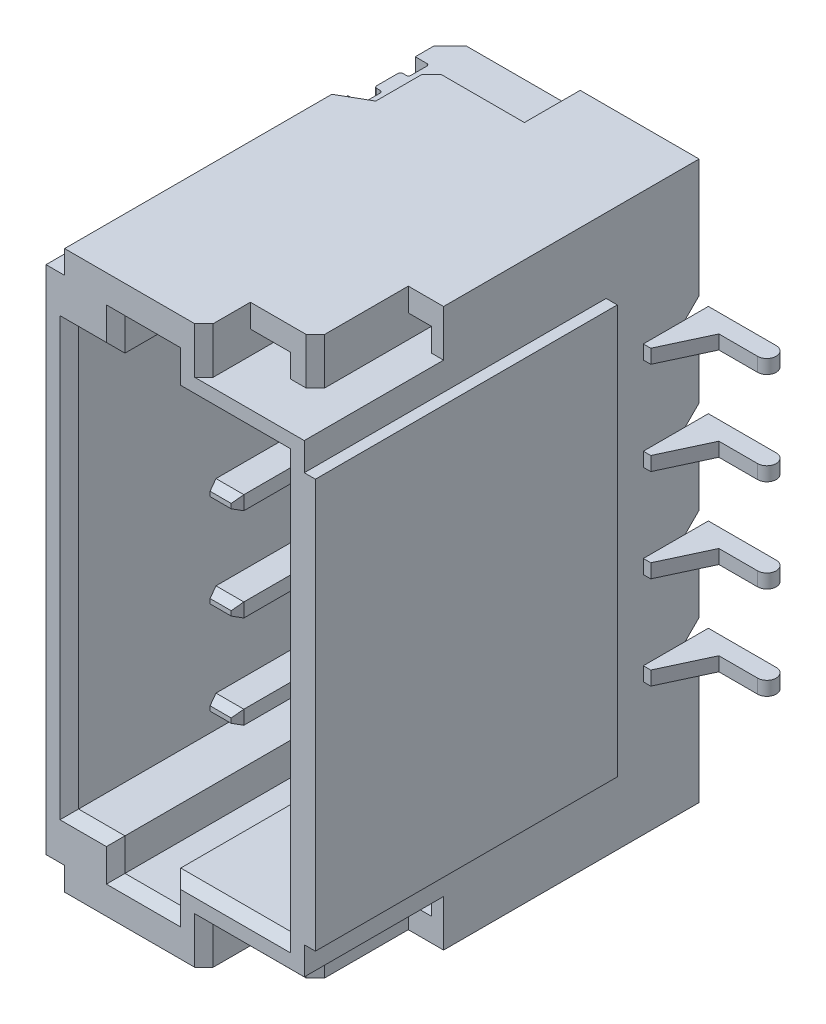
from build123d import *

# Parameters (mm, degrees)
BOSS_EXTRUDE2_START      = -0.815
BOSS_EXTRUDE2_DEPTH      = 0.15
BOSS_EXTRUDE3_START      = 2.26
BOSS_EXTRUDE3_DEPTH      = 0.2
BOSS_EXTRUDE4_START      = 1.76
SKETCH4_W                = 2.899999619
SKETCH4_H                = 6
BOSS_EXTRUDE4_DEPTH      = 4.25
CUT_EXTRUDE2_DEPTH       = 4.610000193
LPATTERN1_COUNT          = 4
LPATTERN1_PITCH          = 1
SKETCH6_OUTSIDE_W        = 7.998
SKETCH6_OUTSIDE_H        = 9.648
SKETCH6_OUTSIDE_W_2      = 3.400752587
SKETCH6_OUTSIDE_H_2      = 4.399999618
CUT_EXTRUDE3_DEPTH       = 0.12
SKETCH7_W                = 2.280000687
SKETCH7_H                = 4.5
CUT_EXTRUDE4_DEPTH       = 3.2
SKETCH8_W                = 0.600000381
SKETCH8_H                = 0.349998474
SKETCH8_H_2              = 0.350000382
CUT_EXTRUDE6_DEPTH       = 2.6
CHAMFER1_SIZE            = 0.1
BOSS_EXTRUDE5_START      = -1.82
BOSS_EXTRUDE5_DEPTH      = 0.15
CHAMFER2_SIZE            = 0.1
CHAMFER2_SIZE2           = 0.05
CHAMFER3_SIZE            = 0.05
CHAMFER3_SIZE2           = 0.1
LPATTERN2_COUNT          = 4
LPATTERN2_PITCH          = 1
SKETCH10_W               = 4.538557702
SKETCH10_H               = 0.25
SKETCH10_W_2             = 4.80487801
CUT_EXTRUDE7_DEPTH       = 0.2
CUT_EXTRUDE8_DEPTH       = 0.5
SKETCH12_W               = 0.600000143
SKETCH12_H               = 0.25
CUT_EXTRUDE9_DEPTH       = 1
CHAMFER4_SIZE            = 0.1
CHAMFER5_SIZE            = 0.1
CHAMFER4_OF_MIRROR1_SIZE = 0.1
CHAMFER5_OF_MIRROR1_SIZE = 0.1
CUT_EXTRUDE10_DEPTH      = 0.5
CHAMFER6_SIZE            = 0.1
SKETCH14_W               = 0.431049877
SKETCH14_H               = 0.25
SKETCH14_W_2             = 0.251151421
CUT_EXTRUDE11_DEPTH      = 2
CHAMFER6_OF_MIRROR3_SIZE = 0.1


with BuildPart() as part:
    # Sketch2 → Boss-Extrude2 (new body)
    with BuildSketch(Plane(origin=(0, 0, 0), x_dir=(1, 0, 0), z_dir=(0, 1, 0)).offset(BOSS_EXTRUDE2_START)):
        with BuildLine():
            Line((22.630613327, -2.360296965), (22.630613327, -1.910297036))
            Line((22.630613327, -1.910297036), (25.410614014, -1.910297036))
            Line((25.410614014, -1.910297036), (25.410614014, -1.660297036))
            Line((25.410614014, -1.660297036), (26.140613556, -1.660297036))
            ThreePointArc((26.140613556, -1.660297036), (26.24061352, -1.760297), (26.140613556, -1.860296965))
            Line((26.140613556, -1.860296965), (25.723766327, -1.860296965))
            Line((25.723766327, -1.860296965), (25.490613937, -2.360296965))
            Line((25.490613937, -2.360296965), (22.630613327, -2.360296965))
        make_face()
    extrude(amount=BOSS_EXTRUDE2_DEPTH)


with BuildPart() as body_2:
    # Body-Move/Copy2: copy of part
    add(part.part.moved(Location((0, -1, 0))))


with BuildPart() as body_3:
    # Body-Move/Copy3: copy of part
    add(part.part.moved(Location((0, 1, 0))))


with BuildPart() as body_4:
    # Body-Move/Copy4: copy of body 3
    add(body_3.part.moved(Location((0, 1, 0))))


with BuildPart() as body_5:
    # Sketch3 → Boss-Extrude3 (new body)
    with BuildSketch(Plane(origin=(0, 0, 0), x_dir=(1, 0, 0), z_dir=(0, 1, 0)).offset(BOSS_EXTRUDE3_START)):
        with BuildLine():
            Line((22.730613708, -2.960297108), (24.130613327, -2.960297108))
            Line((24.130613327, -2.960297108), (24.130613327, -1.835296988))
            Line((24.130613327, -1.835296988), (23.955612183, -1.660297036))
            Line((23.955612183, -1.660297036), (22.805612564, -1.660297036))
            Line((22.805612564, -1.660297036), (22.630613327, -1.835296988))
            Line((22.630613327, -1.835296988), (22.630613327, -2.035296917))
            Line((22.630613327, -2.035296917), (22.755613327, -2.035296917))
            ThreePointArc((22.755613327, -2.035296917), (22.773290756, -2.042619444), (22.780612946, -2.060297012))
            Line((22.780612946, -2.060297012), (22.780612946, -2.232796907))
            ThreePointArc((22.780612946, -2.232796907), (22.773287217, -2.250482782), (22.755601342, -2.257808511))
            Line((22.755601342, -2.257808511), (22.718101914, -2.257808511))
            ThreePointArc((22.718101914, -2.257808511), (22.700432315, -2.265127499), (22.693113327, -2.282797098))
            Line((22.693113327, -2.282797098), (22.693113327, -2.512797117))
            ThreePointArc((22.693113327, -2.512797117), (22.700435531, -2.530474601), (22.718112946, -2.537796974))
            Line((22.718112946, -2.537796974), (22.755613327, -2.537796974))
            ThreePointArc((22.755613327, -2.537796974), (22.773290895, -2.545119362), (22.780612946, -2.56279707))
            Line((22.780612946, -2.56279707), (22.780612946, -2.735296965))
            ThreePointArc((22.780612946, -2.735296965), (22.773290756, -2.752974533), (22.755613327, -2.76029706))
            Line((22.755613327, -2.76029706), (22.630613327, -2.76029706))
            Line((22.630613327, -2.76029706), (22.630613327, -2.860296965))
            Line((22.630613327, -2.860296965), (22.730613708, -2.960297108))
        make_face()
    extrude(amount=BOSS_EXTRUDE3_DEPTH)


with BuildPart() as body_6:
    # Sketch4 → Boss-Extrude4 (new body)
    with BuildSketch(Plane.XY.offset(BOSS_EXTRUDE4_START)):
        with Locations((24.080613137, -0.240909576)):
            Rectangle(SKETCH4_W, SKETCH4_H)
    extrude(amount=BOSS_EXTRUDE4_DEPTH)

    # Sketch5 → Cut-Extrude2 (cut, through all)
    with BuildSketch(Plane.ZY.offset(-22.630613327)):
        Polygon((1.760296941, 1.484088898), (1.910297036, 1.334089279), (2.360296965, 1.334089279), (2.360296965, 1.184089661), (1.910297036, 1.184089661), (1.760296941, 1.034090042), (1.752676685, 1.034090042), (1.752676685, 1.484088898), align=None)
    cut_extrude2 = extrude(amount=-CUT_EXTRUDE2_DEPTH, mode=Mode.SUBTRACT)

    # LPattern1: Cut-Extrude2 ×4
    with Locations(*[(0, -i * LPATTERN1_PITCH, 0) for i in range(1, LPATTERN1_COUNT)]):
        add(cut_extrude2, mode=Mode.SUBTRACT)

    # Sketch6 outside → Cut-Extrude3 (cut)
    with BuildSketch(Plane(origin=(25.530612946, 0, 0), x_dir=(0, 0, -1), z_dir=(1, 0, 0))):
        with Locations((-3.835, -0.241)):
            Rectangle(SKETCH6_OUTSIDE_W, SKETCH6_OUTSIDE_H)
        with Locations((-4.460673354, -0.24091053)):
            Rectangle(SKETCH6_OUTSIDE_W_2, SKETCH6_OUTSIDE_H_2, mode=Mode.SUBTRACT)
    extrude(amount=-CUT_EXTRUDE3_DEPTH, mode=Mode.SUBTRACT)

    # Sketch7 → Cut-Extrude4 (cut)
    with BuildSketch(Plane.XY.offset(6.01)):
        with Locations((24.020613671, -0.240909576)):
            Rectangle(SKETCH7_W, SKETCH7_H)
    extrude(amount=-CUT_EXTRUDE4_DEPTH, mode=Mode.SUBTRACT)

    # Sketch8 → Cut-Extrude6 (cut)
    with BuildSketch(Plane.XY.offset(6.01)):
        with Locations((23.680613517, 2.184089661)):
            Rectangle(SKETCH8_W, SKETCH8_H)
        with Locations((23.680613517, -2.665909767)):
            Rectangle(SKETCH8_W, SKETCH8_H_2)
    extrude(amount=-CUT_EXTRUDE6_DEPTH, mode=Mode.SUBTRACT)

    # Chamfer1
    chamfer1_edges = [body_6.edges().sort_by_distance(p)[0] for p in [
        (22.880613327, -0.240909576, 6.01),
        (23.130613327, -2.490909576, 6.01),
        (25.160614014, -0.240909576, 6.01),
        (24.570613861, 2.009090424, 6.01),
        (24.570613861, -2.490909576, 6.01),
        (23.130613327, 2.009090424, 6.01),
        (23.380613327, 2.184089661, 6.01),
        (23.980613708, 2.184089661, 6.01),
        (23.680613518, 2.359088898, 6.01),
        (23.380613327, -2.665909767, 6.01),
        (23.680613518, -2.840909958, 6.01),
        (23.980613708, -2.665909767, 6.01),
    ]]
    chamfer(chamfer1_edges, length=CHAMFER1_SIZE)

    # Sketch10 → Cut-Extrude7 (cut)
    with BuildSketch(Plane.ZY.offset(-22.630613327)):
        with Locations((3.741017971, 2.634090424)):
            Rectangle(SKETCH10_W, SKETCH10_H)
        with Locations((3.607857817, -3.115909576)):
            Rectangle(SKETCH10_W_2, SKETCH10_H)
    extrude(amount=-CUT_EXTRUDE7_DEPTH, mode=Mode.SUBTRACT)

    # Sketch11 → Cut-Extrude8 (cut)
    with BuildSketch(Plane.XZ.offset(3.240909576)):
        Polygon((22.630613327, 3.248971939), (23.130613327, 2.960297108), (23.130613327, 2.360296965), (24.130613327, 2.360296965), (24.130613327, 1.643555377), (22.630613327, 1.643555377), align=None)
    cut_extrude8 = extrude(amount=-CUT_EXTRUDE8_DEPTH, mode=Mode.SUBTRACT)

    # Sketch12 → Cut-Extrude9 (cut)
    with BuildSketch(Plane.ZY.offset(-23.130613327)):
        with Locations((2.660297037, -2.865909576)):
            Rectangle(SKETCH12_W, SKETCH12_H)
    cut_extrude9 = extrude(amount=-CUT_EXTRUDE9_DEPTH, mode=Mode.SUBTRACT)

    # Chamfer4
    chamfer4_edges = [body_6.edges().sort_by_distance(p)[0] for p in [
        (22.630613327, -2.740909576, 2.50448597),
    ]]
    chamfer(chamfer4_edges, length=CHAMFER4_SIZE)

    # Chamfer5
    chamfer5_edges = [body_6.edges().sort_by_distance(p)[0] for p in [
        (23.130613327, -3.115909576, 2.360296965),
    ]]
    chamfer(chamfer5_edges, length=CHAMFER5_SIZE)

    # Mirror1: Cut-Extrude8, Cut-Extrude9 across plane
    add(cut_extrude8.mirror(Plane(origin=(0, -0.240909576, 0), x_dir=(0, 0, 1), z_dir=(0, -1, 0))), mode=Mode.SUBTRACT)
    add(cut_extrude9.mirror(Plane(origin=(0, -0.240909576, 0), x_dir=(0, 0, 1), z_dir=(0, -1, 0))), mode=Mode.SUBTRACT)

    # Chamfer4 of Mirror1
    chamfer4_of_mirror1_edges = [body_6.edges().sort_by_distance(p)[0] for p in [
        (22.630613327, 2.259090424, 2.50448597),
    ]]
    chamfer(chamfer4_of_mirror1_edges, length=CHAMFER4_OF_MIRROR1_SIZE)

    # Chamfer5 of Mirror1
    chamfer5_of_mirror1_edges = [body_6.edges().sort_by_distance(p)[0] for p in [
        (23.130613327, 2.634090424, 2.360296965),
    ]]
    chamfer(chamfer5_of_mirror1_edges, length=CHAMFER5_OF_MIRROR1_SIZE)

    # Sketch13 → Cut-Extrude10 (cut)
    with BuildSketch(Plane.XZ.offset(3.240909576)):
        Polygon((24.330612183, 5.510296822), (24.330612183, 6.069555527), (25.671033585, 6.069555527), (25.671033585, 4.510296822), (25.030612946, 4.510296822), (25.030612946, 5.510296822), align=None)
    cut_extrude10 = extrude(amount=-CUT_EXTRUDE10_DEPTH, mode=Mode.SUBTRACT)

    # Chamfer6
    chamfer6_edges = [body_6.edges().sort_by_distance(p)[0] for p in [
        (24.330612183, -2.990909576, 6.01),
        (25.030612946, -2.990909576, 5.510296822),
    ]]
    chamfer(chamfer6_edges, length=CHAMFER6_SIZE)

    # Sketch14 → Cut-Extrude11 (cut)
    with BuildSketch(Plane.XY.offset(5.510296822)):
        with Locations((24.546137122, -2.865909576)):
            Rectangle(SKETCH14_W, SKETCH14_H)
        with Locations((25.156188656, -2.865909576)):
            Rectangle(SKETCH14_W_2, SKETCH14_H)
    cut_extrude11 = extrude(amount=-CUT_EXTRUDE11_DEPTH, mode=Mode.SUBTRACT)

    # Mirror3: Cut-Extrude10, Cut-Extrude11 across plane
    add(cut_extrude10.mirror(Plane(origin=(0, -0.240909576, 0), x_dir=(0, 0, 1), z_dir=(0, -1, 0))), mode=Mode.SUBTRACT)
    add(cut_extrude11.mirror(Plane(origin=(0, -0.240909576, 0), x_dir=(0, 0, 1), z_dir=(0, -1, 0))), mode=Mode.SUBTRACT)

    # Chamfer6 of Mirror3
    chamfer6_of_mirror3_edges = [body_6.edges().sort_by_distance(p)[0] for p in [
        (24.330612183, 2.509090424, 6.01),
        (25.030612946, 2.509090424, 5.510296822),
    ]]
    chamfer(chamfer6_of_mirror3_edges, length=CHAMFER6_OF_MIRROR3_SIZE)


with BuildPart() as body_7:
    # Sketch9 → Boss-Extrude5 (new body)
    with BuildSketch(Plane(origin=(0, 0, 0), x_dir=(1, 0, 0), z_dir=(0, 1, 0)).offset(BOSS_EXTRUDE5_START)):
        Polygon((23.360612869, -2.810297012), (23.660614014, -2.810297012), (23.660614014, -4.910296917), (23.62421608, -5.010296822), (23.397010803, -5.010296822), (23.360612869, -4.910296917), align=None)
    extrude(amount=BOSS_EXTRUDE5_DEPTH)

    # Chamfer2
    chamfer2_edges = [body_7.edges().sort_by_distance(p)[0] for p in [
        (23.510613441, -1.82, 5.010296822),
    ]]
    chamfer2_side = [body_7.faces().sort_by_distance(p)[0] for p in [
        (23.510613441, -1.82, 3.90438183),
    ]]
    chamfer(chamfer2_edges, length=CHAMFER2_SIZE, length2=CHAMFER2_SIZE2, reference=chamfer2_side[0])

    # Chamfer3
    chamfer3_edges = [body_7.edges().sort_by_distance(p)[0] for p in [
        (23.510613441, -1.67, 5.010296822),
    ]]
    chamfer3_side = [body_7.faces().sort_by_distance(p)[0] for p in [
        (23.510613441, -1.72, 5.010296822),
    ]]
    chamfer(chamfer3_edges, length=CHAMFER3_SIZE, length2=CHAMFER3_SIZE2, reference=chamfer3_side[0])


with BuildPart() as lpattern2_1:
    # LPattern2: pattern copy
    add(body_7.part.moved(Location(Vector(0, 1, 0) * (1 * LPATTERN2_PITCH))))


with BuildPart() as lpattern2_2:
    # LPattern2: pattern copy
    add(body_7.part.moved(Location(Vector(0, 1, 0) * (2 * LPATTERN2_PITCH))))


with BuildPart() as lpattern2_3:
    # LPattern2: pattern copy
    add(body_7.part.moved(Location(Vector(0, 1, 0) * (3 * LPATTERN2_PITCH))))


with BuildPart() as body_11:
    # Mirror2: mirrored copy
    add(body_5.part.mirror(Plane(origin=(0, -0.240909576, 0), x_dir=(0, 0, 1), z_dir=(0, -1, 0))))


solid = Compound([part.part, body_2.part, body_3.part, body_4.part, body_5.part, body_6.part, body_7.part, lpattern2_1.part, lpattern2_2.part, lpattern2_3.part, body_11.part])
